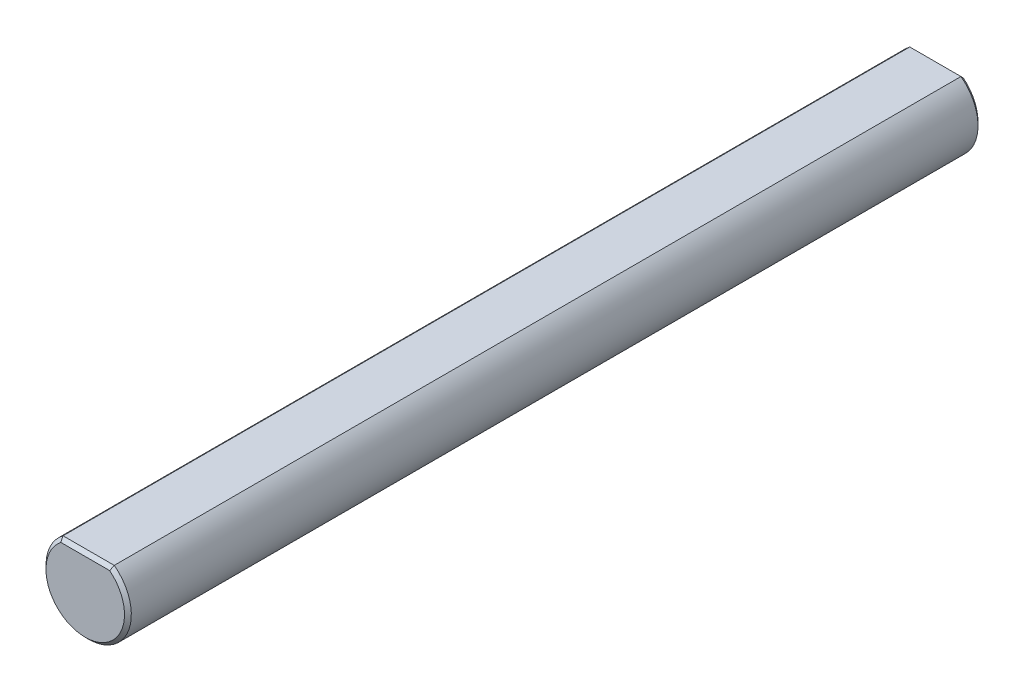
from build123d import *

# Parameters (mm, degrees)
BOSS_EXTRUDE1_DEPTH = 25
CHAMFER1_SIZE       = 0.2


with BuildPart() as part:
    # Sketch1 → Boss-Extrude1 (new body, symmetric)
    with BuildSketch(Plane.XY):
        with BuildLine():
            Line((1.5, 2), (-1.5, 2))
            ThreePointArc((-1.5, 2), (-1.118033989, -2.236067977), (2.5, 0))
            ThreePointArc((2.5, 0), (2.236067977, 1.118033989), (1.5, 2))
        make_face()
    extrude(amount=BOSS_EXTRUDE1_DEPTH, both=True)

    # Chamfer1
    chamfer1_edges = [part.edges().sort_by_distance(p)[0] for p in [
        (0, 2, -25),
        (0, -2.5, 25),
        (0, -2.5, -25),
        (0, 2, 25),
    ]]
    chamfer(chamfer1_edges, length=CHAMFER1_SIZE)


solid = part.part
